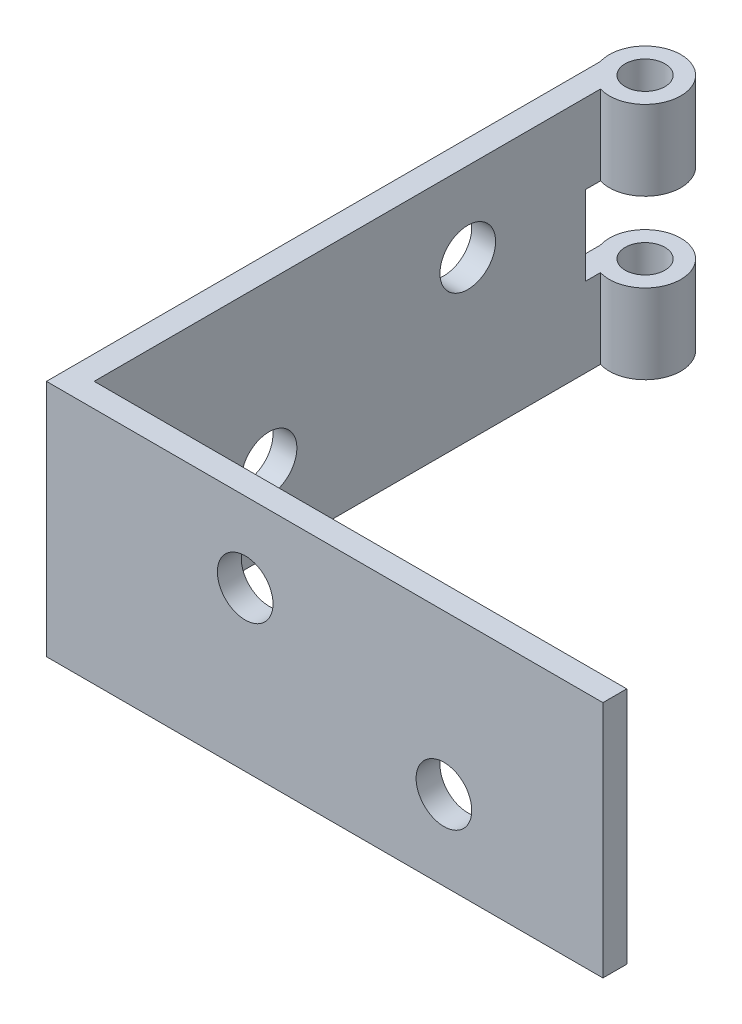
from build123d import *

# Parameters (mm, degrees)
EXTRUDE_1_DEPTH          = 30
SKETCH_2_R               = 3.5
CUT_EXTRUDE_1_DEPTH      = 71
SKETCH_3_R               = 3.5
CUT_EXTRUDE_2_DEPTH      = 71
SKETCH_4_R               = 4.5
SKETCH_4_R_2             = 2.5
EXTRUDE_2_DEPTH          = 30
SKETCH_5_R               = 2.5
CUT_EXTRUDE_6_DEPTH      = 31
SKETCH_6_W               = 11.97763243
SKETCH_6_H               = 9.98933257
CUT_EXTRUDE_8_DEPTH      = 71
CUT_EXTRUDE_8_DEPTH_BACK = 1.2


with BuildPart() as part:
    # Эскиз1 → Вытянуть-Тонкостенный1 (new body)
    with BuildSketch(Plane(origin=(0, 0, 0), x_dir=(1, 0, 0), z_dir=(0, 1, 0))):
        Polygon((0, 70), (0, 0), (70, 0), (70, 3), (3, 3), (3, 70), align=None)
    extrude(amount=EXTRUDE_1_DEPTH)

    # Эскиз2 → Вырез-Вытянуть1 (cut, through all)
    with BuildSketch(Plane.ZY):
        with Locations((-50, 20)):
            Circle(SKETCH_2_R)
        with Locations((-25, 10)):
            Circle(SKETCH_2_R)
    extrude(amount=-CUT_EXTRUDE_1_DEPTH, mode=Mode.SUBTRACT)

    # Эскиз3 → Вырез-Вытянуть2 (cut, through all)
    with BuildSketch(Plane.XY):
        with Locations((25, 20)):
            Circle(SKETCH_3_R)
        with Locations((50, 10)):
            Circle(SKETCH_3_R)
    extrude(amount=-CUT_EXTRUDE_2_DEPTH, mode=Mode.SUBTRACT)

    # Эскиз4 → Вытянуть-Тонкостенный2 (add)
    with BuildSketch(Plane(origin=(0, 0, 0), x_dir=(1, 0, 0), z_dir=(0, 1, 0))):
        with Locations((4.3, 71)):
            Circle(SKETCH_4_R)
        with Locations((4.3, 71)):
            Circle(SKETCH_4_R_2, mode=Mode.SUBTRACT)
    extrude(amount=EXTRUDE_2_DEPTH)

    # Эскиз5 → Вырез-Вытянуть6 (cut, through all)
    with BuildSketch(Plane(origin=(0, 0, 0), x_dir=(1, 0, 0), z_dir=(0, 1, 0))):
        with Locations((4.3, 71)):
            Circle(SKETCH_5_R)
    extrude(amount=CUT_EXTRUDE_6_DEPTH, mode=Mode.SUBTRACT)

    # Эскиз6 → Вырез-Вытянуть8 (cut, two sides)
    with BuildSketch(Plane(origin=(0, 0, 0), x_dir=(0, 0, -1), z_dir=(1, 0, 0))) as cut_extrude_8_sk:
        with Locations((70.813459228, 14.994666285)):
            Rectangle(SKETCH_6_W, SKETCH_6_H)
    extrude(amount=CUT_EXTRUDE_8_DEPTH, mode=Mode.SUBTRACT)
    extrude(cut_extrude_8_sk.sketch, amount=-CUT_EXTRUDE_8_DEPTH_BACK, mode=Mode.SUBTRACT)


solid = part.part
